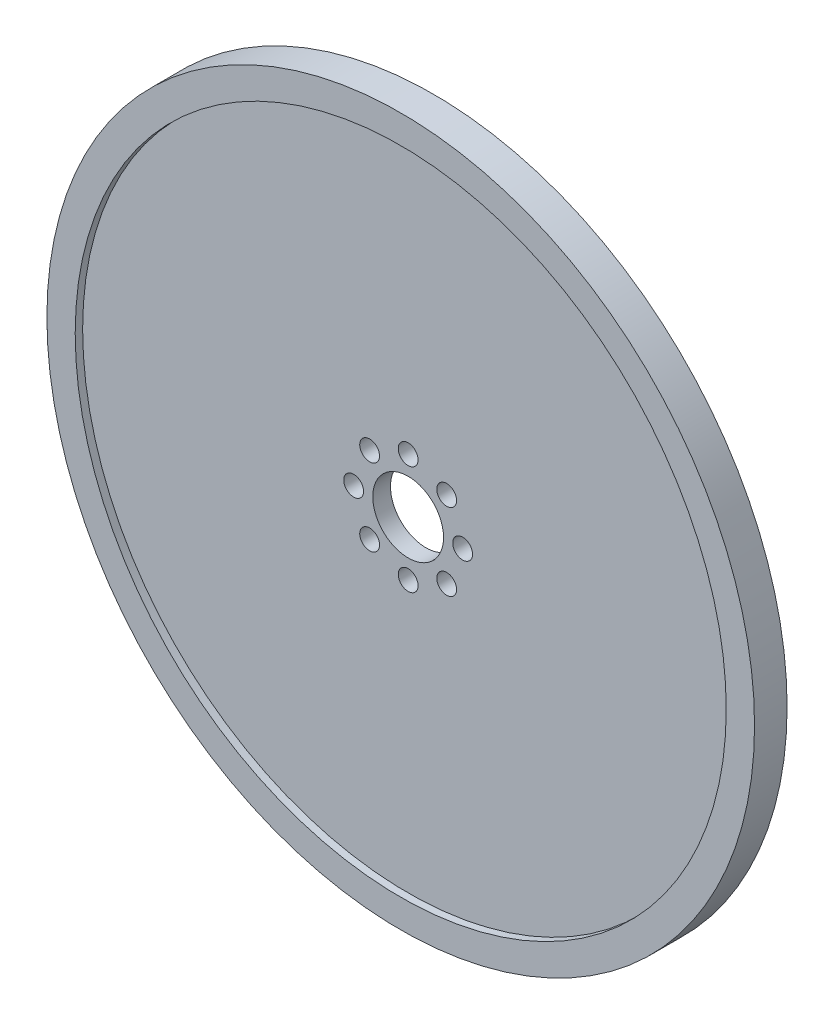
from build123d import *

# Parameters (mm, degrees)
SKETCH1_R           = 63.5
SKETCH1_R_2         = 58.42
BOSS_EXTRUDE1_DEPTH = 2.921
SKETCH3_R           = 58.42
SKETCH3_R_2         = 6.35
SKETCH3_R_3         = 1.778
BOSS_EXTRUDE2_DEPTH = 1.5875


with BuildPart() as part:
    # Sketch1 → Boss-Extrude1 (new body, symmetric)
    with BuildSketch(Plane.XY):
        Circle(SKETCH1_R)
        Circle(SKETCH1_R_2, mode=Mode.SUBTRACT)
    extrude(amount=BOSS_EXTRUDE1_DEPTH, both=True)

    # Sketch3 → Boss-Extrude2 (add, symmetric)
    with BuildSketch(Plane.XY):
        Circle(SKETCH3_R)
        Circle(SKETCH3_R_2, mode=Mode.SUBTRACT)
        with Locations((0, 9.779)):
            Circle(SKETCH3_R_3, mode=Mode.SUBTRACT)
        with Locations((6.914797213, 6.914797213)):
            Circle(SKETCH3_R_3, mode=Mode.SUBTRACT)
        with Locations((9.779, 0)):
            Circle(SKETCH3_R_3, mode=Mode.SUBTRACT)
        with Locations((6.914797213, -6.914797213)):
            Circle(SKETCH3_R_3, mode=Mode.SUBTRACT)
        with Locations((0, -9.779)):
            Circle(SKETCH3_R_3, mode=Mode.SUBTRACT)
        with Locations((-6.914797213, -6.914797213)):
            Circle(SKETCH3_R_3, mode=Mode.SUBTRACT)
        with Locations((-9.779, 0)):
            Circle(SKETCH3_R_3, mode=Mode.SUBTRACT)
        with Locations((-6.914797213, 6.914797213)):
            Circle(SKETCH3_R_3, mode=Mode.SUBTRACT)
    extrude(amount=BOSS_EXTRUDE2_DEPTH, both=True)


solid = part.part
